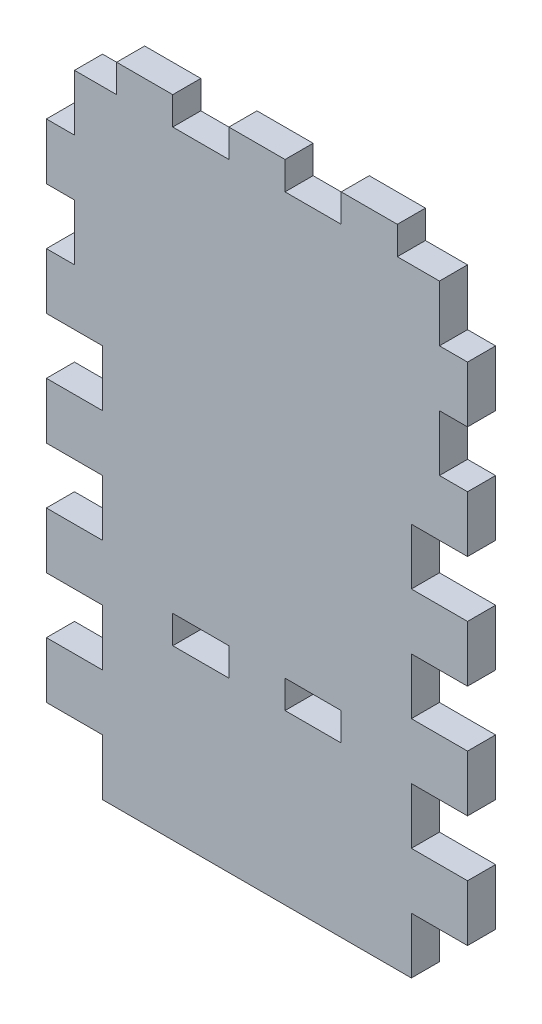
from build123d import *

# Parameters (mm, degrees)
SKETCH1_W           = 95.25
SKETCH1_H           = 177.8
BOSS_EXTRUDE1_DEPTH = 6.35
SKETCH2_W           = 12.7
SKETCH2_H           = 12.7
CUT_EXTRUDE1_DEPTH  = 7.35
LPATTERN1_COUNT     = 4
LPATTERN1_PITCH     = 25.4
SKETCH3_W           = 12.7
SKETCH3_H           = 6.35
CUT_EXTRUDE2_DEPTH  = 7.35
SKETCH5_W           = 6.35
SKETCH5_H           = 12.7
CUT_EXTRUDE4_DEPTH  = 7.35
LPATTERN2_COUNT     = 4
LPATTERN2_PITCH     = 25.4
SKETCH6_W           = 95.25
SKETCH6_H           = 38.1
CUT_EXTRUDE5_DEPTH  = 7.35
SKETCH7_W           = 12.7
SKETCH7_H           = 6.35
BOSS_EXTRUDE2_DEPTH = 6.35
LPATTERN3_COUNT     = 2
LPATTERN3_PITCH     = 25.4
LPATTERN3_COL_COUNT = 2
LPATTERN3_COL_PITCH = 25.4


with BuildPart() as part:
    # Sketch1 → Boss-Extrude1 (new body)
    with BuildSketch(Plane.XY):
        with Locations((47.625, 88.9)):
            Rectangle(SKETCH1_W, SKETCH1_H)
    extrude(amount=BOSS_EXTRUDE1_DEPTH)

    # Sketch2 → Cut-Extrude1 (cut, through all)
    with BuildSketch(Plane.XY.offset(6.35)):
        with Locations((6.35, 6.35)):
            Rectangle(SKETCH2_W, SKETCH2_H)
        with Locations((88.9, 6.35)):
            Rectangle(SKETCH2_W, SKETCH2_H)
    cut_extrude1 = extrude(amount=-CUT_EXTRUDE1_DEPTH, mode=Mode.SUBTRACT)

    # LPattern1: Cut-Extrude1 ×4
    with Locations(*[(0, i * LPATTERN1_PITCH, 0) for i in range(1, LPATTERN1_COUNT)]):
        add(cut_extrude1, mode=Mode.SUBTRACT)

    # Sketch3 → Cut-Extrude2 (cut, through all)
    with BuildSketch(Plane.XY.offset(6.35)):
        with Locations((34.925, 41.275)):
            Rectangle(SKETCH3_W, SKETCH3_H)
        with Locations((60.325, 41.275)):
            Rectangle(SKETCH3_W, SKETCH3_H)
    extrude(amount=-CUT_EXTRUDE2_DEPTH, mode=Mode.SUBTRACT)

    # Sketch5 → Cut-Extrude4 (cut, through all)
    with BuildSketch(Plane.XY.offset(6.35)):
        with Locations((3.175, 107.95)):
            Rectangle(SKETCH5_W, SKETCH5_H)
        with Locations((92.075, 107.95)):
            Rectangle(SKETCH5_W, SKETCH5_H)
    cut_extrude4 = extrude(amount=-CUT_EXTRUDE4_DEPTH, mode=Mode.SUBTRACT)

    # LPattern2: Cut-Extrude4 ×4
    with Locations(*[(0, i * LPATTERN2_PITCH, 0) for i in range(1, LPATTERN2_COUNT)]):
        add(cut_extrude4, mode=Mode.SUBTRACT)

    # Sketch6 → Cut-Extrude5 (cut, through all)
    with BuildSketch(Plane.XY.offset(6.35)):
        with Locations((47.625, 158.75)):
            Rectangle(SKETCH6_W, SKETCH6_H)
    extrude(amount=-CUT_EXTRUDE5_DEPTH, mode=Mode.SUBTRACT)

    # Sketch7 → Boss-Extrude2 (add)
    with BuildSketch(Plane(origin=(0, 139.7, 0), x_dir=(1, 0, 0), z_dir=(0, 1, 0))):
        with Locations((47.625, -3.175)):
            Rectangle(SKETCH7_W, SKETCH7_H)
    boss_extrude2 = extrude(amount=BOSS_EXTRUDE2_DEPTH)

    # LPattern3: Boss-Extrude2 ×2
    with Locations(*[(i * LPATTERN3_PITCH, 0, 0) for i in range(1, LPATTERN3_COUNT)]):
        add(boss_extrude2)

    # LPattern3 col: Boss-Extrude2 ×2
    with Locations(*[(-i * LPATTERN3_COL_PITCH, 0, 0) for i in range(1, LPATTERN3_COL_COUNT)]):
        add(boss_extrude2)


solid = part.part
